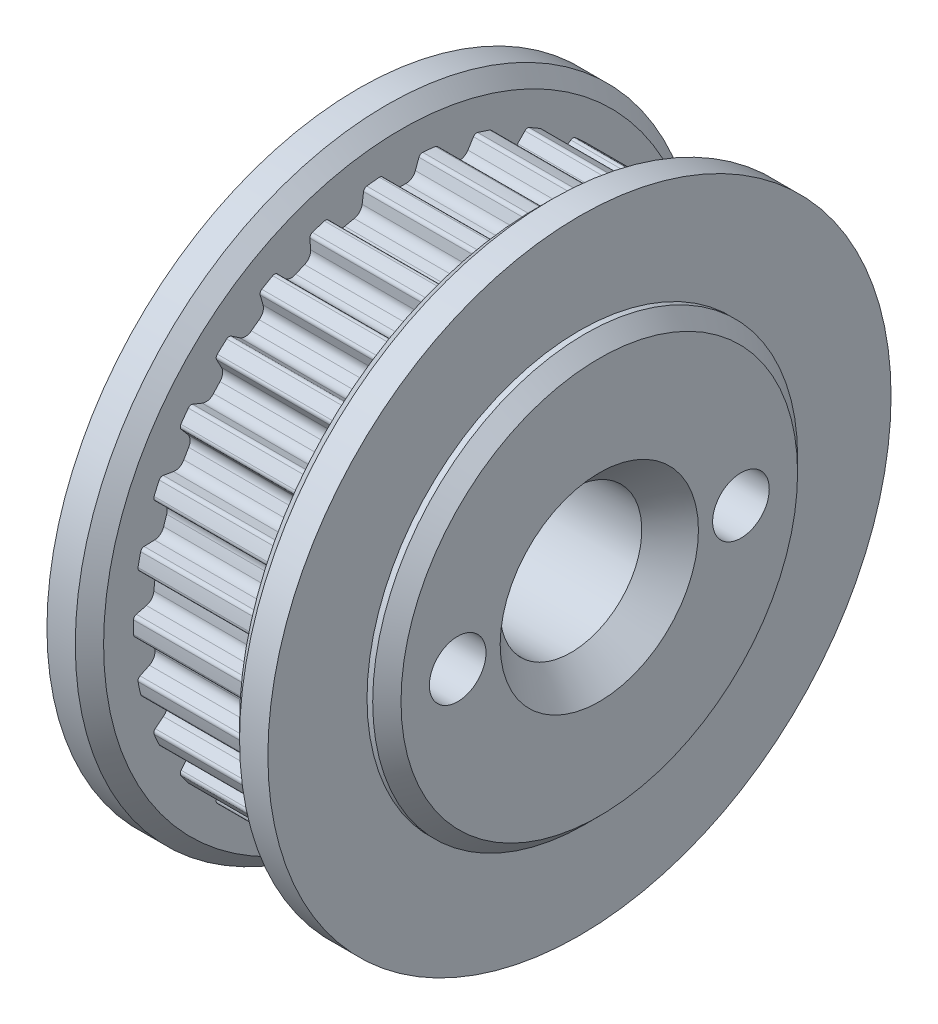
from build123d import *

# Parameters (mm, degrees)
SKETCH_7_R               = 11
SKETCH_7_R_2             = 1.75
EXTRUDE_1_DEPTH          = 1.5
SKETCH_8_R               = 2.5
CUT_EXTRUDE_3_DEPTH      = 9.5
CHAMFER_1_SIZE           = 1
CUT_EXTRUDE_2_DEPTH      = 4.8
PATTERN_CIRCULAR_3_COUNT = 30
SKETCH_10_R              = 7.5
SKETCH_10_R_2            = 5
EXTRUDE_3_DEPTH          = 2.2
CHAMFER_2_SIZE           = 0.5
MM_CLEARANCE_1_D         = 2
SKETCH_9_R               = 11
SKETCH_9_R_2             = 7.5
EXTRUDE_2_DEPTH          = 1.5
CHAMFER_3_SIZE           = 0.5


with BuildPart() as part:
    # 草图1 → 旋转1 (revolve)
    with BuildSketch(Plane.XY):
        Polygon((0, 1.75), (0, 9.446), (4.8, 9.446), (4.8, 5), (7, 5), (7, 1.75), align=None)
    revolve(axis=Axis((0, 0, 0), (1, 0, 0)))

    # 草图7 → 凸台-拉伸1 (add)
    with BuildSketch(Plane.ZY):
        Circle(SKETCH_7_R)
        Circle(SKETCH_7_R_2, mode=Mode.SUBTRACT)
    extrude(amount=EXTRUDE_1_DEPTH)

    # 草图8 → 切除-拉伸3 (cut, through all)
    with BuildSketch(Plane(origin=(7, 0, 0), x_dir=(0, 0, -1), z_dir=(1, 0, 0))):
        Circle(SKETCH_8_R)
    extrude(amount=-CUT_EXTRUDE_3_DEPTH, mode=Mode.SUBTRACT)

    # 倒角1
    chamfer_1_edges = [part.edges().sort_by_distance(p)[0] for p in [
        (7, 0, 2.5),
        (-1.5, 0, 2.5),
    ]]
    chamfer(chamfer_1_edges, length=CHAMFER_1_SIZE)

    # 草图6 → 切除-拉伸2 (cut)
    with BuildSketch(Plane(origin=(0, 0, 0), x_dir=(0, 0, -1), z_dir=(1, 0, 0))):
        with BuildLine():
            Line((0.632530376, 9.329843514), (0.50685519, 8.984553779))
            ThreePointArc((0.50685519, 8.984553779), (0.375903219, 8.815609518), (0.171122561, 8.754327677))
            ThreePointArc((0.171122561, 8.754327677), (0, 8.756), (-0.171122561, 8.754327677))
            ThreePointArc((-0.171122561, 8.754327677), (-0.375903219, 8.815609518), (-0.50685519, 8.984553779))
            Line((-0.50685519, 8.984553779), (-0.632530376, 9.329843514))
            ThreePointArc((-0.632530376, 9.329843514), (-0.684503697, 9.394805867), (-0.765221734, 9.414953622))
            ThreePointArc((-0.765221734, 9.414953622), (-0.82998998, 9.409465056), (-0.894718924, 9.403530935))
            Line((-0.894718924, 9.403530935), (-1.392814798, 10.772038102))
            ThreePointArc((-1.392814798, 10.772038102), (0, 10.861709715), (1.392814798, 10.772038102))
            Line((1.392814798, 10.772038102), (0.894718924, 9.403530935))
            ThreePointArc((0.894718924, 9.403530935), (0.82998998, 9.409465056), (0.765221734, 9.414953622))
            ThreePointArc((0.765221734, 9.414953622), (0.684503697, 9.394805867), (0.632530376, 9.329843514))
        make_face()
    cut_extrude_2 = extrude(amount=CUT_EXTRUDE_2_DEPTH, mode=Mode.SUBTRACT)

    # 阵列(圆周)3: 切除-拉伸2 ×30 about axis
    pattern_circular_3_axis = Axis((0, 0, 0), (1, 0, 0))
    for i in range(1, PATTERN_CIRCULAR_3_COUNT):
        add(cut_extrude_2.rotate(pattern_circular_3_axis, i * 360 / PATTERN_CIRCULAR_3_COUNT), mode=Mode.SUBTRACT)

    # 草图10 → 凸台-拉伸3 (add)
    with BuildSketch(Plane(origin=(4.8, 0, 0), x_dir=(0, 0, -1), z_dir=(1, 0, 0))):
        Circle(SKETCH_10_R)
        Circle(SKETCH_10_R_2, mode=Mode.SUBTRACT)
    extrude(amount=EXTRUDE_3_DEPTH)

    # 倒角2
    chamfer_2_edges = [part.edges().sort_by_distance(p)[0] for p in [
        (0, 0, -11),
        (7, 0, 7.5),
    ]]
    chamfer(chamfer_2_edges, length=CHAMFER_2_SIZE)

    # 大小mm Clearance 暗销孔1 (through all)
    with Locations(Plane(origin=(7, 0, 0), x_dir=(0, 0, -1), z_dir=(1, 0, 0))):
        with Locations((-5, 0), (5, 0)):
            Hole(MM_CLEARANCE_1_D / 2)


with BuildPart() as body_2:
    # 草图9 → 凸台-拉伸2 (new body)
    with BuildSketch(Plane(origin=(4.8, 0, 0), x_dir=(0, 0, -1), z_dir=(1, 0, 0))):
        Circle(SKETCH_9_R)
        Circle(SKETCH_9_R_2, mode=Mode.SUBTRACT)
    extrude(amount=EXTRUDE_2_DEPTH)

    # 倒角3
    chamfer_3_edges = [body_2.edges().sort_by_distance(p)[0] for p in [
        (4.8, 0, 11),
        (4.8, 0, 7.5),
    ]]
    chamfer(chamfer_3_edges, length=CHAMFER_3_SIZE)


solid = Compound([part.part, body_2.part])
